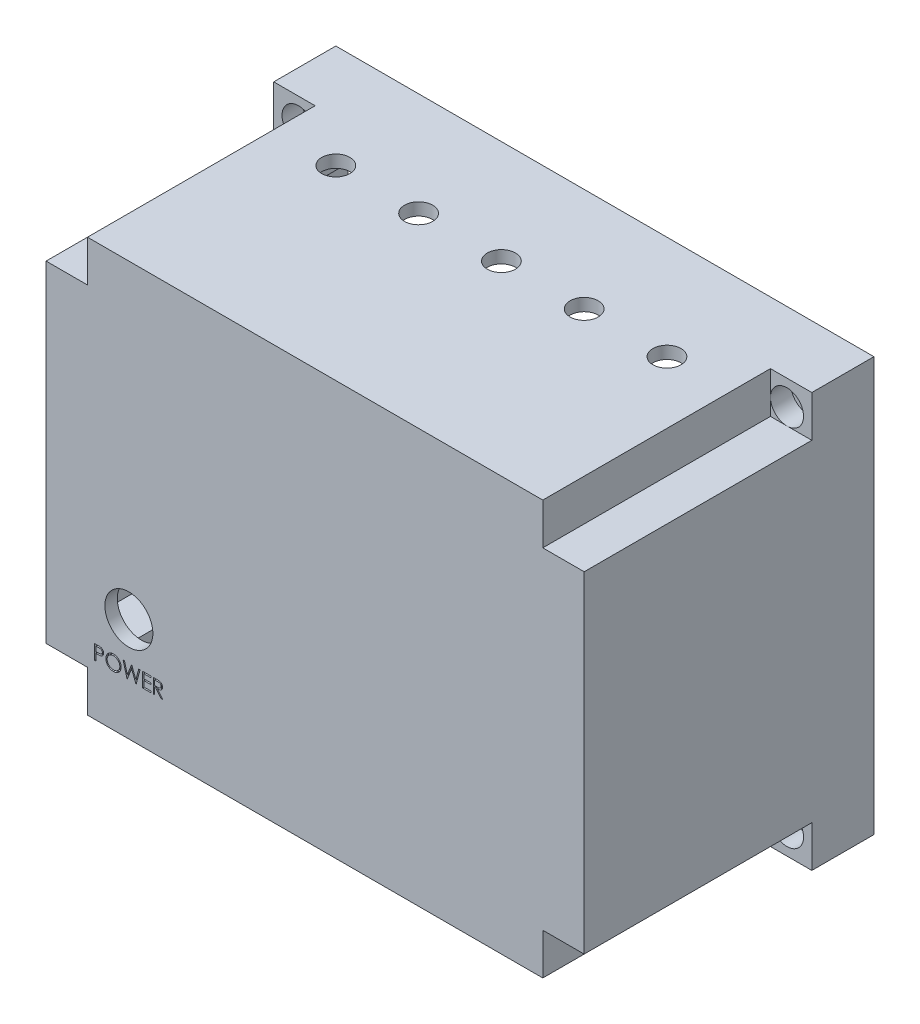
from build123d import *

# Parameters (mm, degrees)
SKETCH2_W           = 130
SKETCH2_H           = 70
BOSS_EXTRUDE1_DEPTH = 100
SKETCH3_W           = 104
SKETCH3_H           = 74
CUT_EXTRUDE1_DEPTH  = 67
SKETCH4_W           = 10
SKETCH4_H           = 10
CUT_EXTRUDE2_DEPTH  = 55
SKETCH5_W           = 104
SKETCH5_H           = 10
CUT_EXTRUDE3_DEPTH  = 67
SKETCH6_W           = 10
SKETCH6_H           = 74
CUT_EXTRUDE4_DEPTH  = 67
SKETCH9_R           = 1.75
CUT_EXTRUDE5_DEPTH  = 67
SKETCH10_R          = 4
CUT_EXTRUDE6_DEPTH  = 5
SKETCH12_R          = 4
CUT_EXTRUDE7_DEPTH  = 5
SKETCH13_R          = 4
CUT_EXTRUDE8_DEPTH  = 5
SKETCH14_R          = 4
CUT_EXTRUDE9_DEPTH  = 5
SKETCH15_W          = 3
SKETCH15_H          = 3
BOSS_EXTRUDE2_DEPTH = 5
SKETCH16_W          = 76
SKETCH16_H          = 3
BOSS_EXTRUDE3_DEPTH = 15
SKETCH17_W          = 3
SKETCH17_H          = 30
BOSS_EXTRUDE4_DEPTH = 15
SKETCH18_R          = 5.8
CUT_EXTRUDE10_DEPTH = 15
SKETCH19_R          = 3.4
CUT_EXTRUDE11_DEPTH = 15
CUT_EXTRUDE12_DEPTH = 0.5


with BuildPart() as part:
    # Sketch2 → Boss-Extrude1 (new body)
    with BuildSketch(Plane(origin=(0, 0, 0), x_dir=(1, 0, 0), z_dir=(0, 1, 0))):
        with Locations((65, 35)):
            Rectangle(SKETCH2_W, SKETCH2_H)
    extrude(amount=BOSS_EXTRUDE1_DEPTH)

    # Sketch3 → Cut-Extrude1 (cut)
    with BuildSketch(Plane(origin=(0, 0, -70), x_dir=(-1, 0, 0), z_dir=(0, 0, -1))):
        with Locations((-65, 50)):
            Rectangle(SKETCH3_W, SKETCH3_H)
    extrude(amount=-CUT_EXTRUDE1_DEPTH, mode=Mode.SUBTRACT)

    # Sketch4 → Cut-Extrude2 (cut)
    with BuildSketch(Plane.XY):
        with Locations((5, 95)):
            Rectangle(SKETCH4_W, SKETCH4_H)
        with Locations((125, 95)):
            Rectangle(SKETCH4_W, SKETCH4_H)
        with Locations((5, 5)):
            Rectangle(SKETCH4_W, SKETCH4_H)
        with Locations((125, 5)):
            Rectangle(SKETCH4_W, SKETCH4_H)
    extrude(amount=-CUT_EXTRUDE2_DEPTH, mode=Mode.SUBTRACT)

    # Sketch5 → Cut-Extrude3 (cut)
    with BuildSketch(Plane(origin=(0, 0, -70), x_dir=(-1, 0, 0), z_dir=(0, 0, -1))):
        with Locations((-65, 92)):
            Rectangle(SKETCH5_W, SKETCH5_H)
        with Locations((-65, 8)):
            Rectangle(SKETCH5_W, SKETCH5_H)
    extrude(amount=-CUT_EXTRUDE3_DEPTH, mode=Mode.SUBTRACT)

    # Sketch6 → Cut-Extrude4 (cut)
    with BuildSketch(Plane(origin=(0, 0, -70), x_dir=(-1, 0, 0), z_dir=(0, 0, -1))):
        with Locations((-122, 50)):
            Rectangle(SKETCH6_W, SKETCH6_H)
        with Locations((-8, 50)):
            Rectangle(SKETCH6_W, SKETCH6_H)
    extrude(amount=-CUT_EXTRUDE4_DEPTH, mode=Mode.SUBTRACT)

    # Sketch9 → Cut-Extrude5 (cut)
    with BuildSketch(Plane(origin=(0, 0, -70), x_dir=(-1, 0, 0), z_dir=(0, 0, -1))):
        with Locations((-124, 94)):
            Circle(SKETCH9_R)
        with Locations((-124, 6)):
            Circle(SKETCH9_R)
        with Locations((-6, 94)):
            Circle(SKETCH9_R)
        with Locations((-6, 6)):
            Circle(SKETCH9_R)
    extrude(amount=-CUT_EXTRUDE5_DEPTH, mode=Mode.SUBTRACT)

    # Sketch10 → Cut-Extrude6 (cut)
    with BuildSketch(Plane.XY.offset(-55)):
        with Locations((124, 94)):
            Circle(SKETCH10_R)
    extrude(amount=-CUT_EXTRUDE6_DEPTH, mode=Mode.SUBTRACT)

    # Sketch12 → Cut-Extrude7 (cut)
    with BuildSketch(Plane.XY.offset(-55)):
        with Locations((124, 6)):
            Circle(SKETCH12_R)
    extrude(amount=-CUT_EXTRUDE7_DEPTH, mode=Mode.SUBTRACT)

    # Sketch13 → Cut-Extrude8 (cut)
    with BuildSketch(Plane.XY.offset(-55)):
        with Locations((6, 6)):
            Circle(SKETCH13_R)
    extrude(amount=-CUT_EXTRUDE8_DEPTH, mode=Mode.SUBTRACT)

    # Sketch14 → Cut-Extrude9 (cut)
    with BuildSketch(Plane.XY.offset(-55)):
        with Locations((6, 94)):
            Circle(SKETCH14_R)
    extrude(amount=-CUT_EXTRUDE9_DEPTH, mode=Mode.SUBTRACT)

    # Sketch15 → Boss-Extrude2 (add)
    with BuildSketch(Plane(origin=(0, 0, -70), x_dir=(-1, 0, 0), z_dir=(0, 0, -1))):
        with Locations((-118.5, 88.5)):
            Rectangle(SKETCH15_W, SKETCH15_H)
        with Locations((-118.5, 11.5)):
            Rectangle(SKETCH15_W, SKETCH15_H)
        with Locations((-11.5, 11.5)):
            Rectangle(SKETCH15_W, SKETCH15_H)
        with Locations((-11.5, 88.5)):
            Rectangle(SKETCH15_W, SKETCH15_H)
    extrude(amount=BOSS_EXTRUDE2_DEPTH)

    # Sketch16 → Boss-Extrude3 (add)
    with BuildSketch(Plane(origin=(0, 3, 0), x_dir=(1, 0, 0), z_dir=(0, 1, 0))):
        with Locations((79, 68.5)):
            Rectangle(SKETCH16_W, SKETCH16_H)
    extrude(amount=BOSS_EXTRUDE3_DEPTH)

    # Sketch17 → Boss-Extrude4 (add)
    with BuildSketch(Plane(origin=(0, 0, -3), x_dir=(-1, 0, 0), z_dir=(0, 0, -1))):
        with Locations((-99.5, 33)):
            Rectangle(SKETCH17_W, SKETCH17_H)
        with Locations((-36.5, 33)):
            Rectangle(SKETCH17_W, SKETCH17_H)
    extrude(amount=BOSS_EXTRUDE4_DEPTH)

    # Sketch18 → Cut-Extrude10 (cut)
    with BuildSketch(Plane(origin=(0, 0, -3), x_dir=(-1, 0, 0), z_dir=(0, 0, -1))):
        with Locations((-20, 25)):
            Circle(SKETCH18_R)
    extrude(amount=-CUT_EXTRUDE10_DEPTH, mode=Mode.SUBTRACT)

    # Sketch19 → Cut-Extrude11 (cut)
    with BuildSketch(Plane(origin=(0, 100, 0), x_dir=(1, 0, 0), z_dir=(0, 1, 0))):
        with Locations((25, 45)):
            Circle(SKETCH19_R)
        with Locations((45, 45)):
            Circle(SKETCH19_R)
        with Locations((65, 45)):
            Circle(SKETCH19_R)
        with Locations((85, 45)):
            Circle(SKETCH19_R)
        with Locations((105, 45)):
            Circle(SKETCH19_R)
    extrude(amount=-CUT_EXTRUDE11_DEPTH, mode=Mode.SUBTRACT)

    # Sketch20 → Cut-Extrude12 (cut)
    with BuildSketch(Plane.XY):
        with BuildLine():
            Line((11.755848819, 15.843775978), (12.442247056, 15.843775978))
            add(Edge.make_bspline(
                [(12.442247056, 15.843775978), (12.489457962, 15.843724082), (12.579916155, 15.843624646), (12.709631211, 15.8406099), (12.827440942, 15.836583208), (12.933091323, 15.831001315), (13.026907421, 15.824404725), (13.108464721, 15.815152686), (13.178404277, 15.80549239), (13.220310727, 15.795670983), (13.239422537, 15.791191843)],
                knots=[0, 0, 0, 0, 0.000141628, 0.000271366, 0.00038923, 0.000495248, 0.00058876, 0.000671296, 0.000741499, 0.00080036, 0.00080036, 0.00080036, 0.00080036], degree=3))
            add(Edge.make_bspline(
                [(13.239422537, 15.791191843), (13.263616071, 15.784569894), (13.311433048, 15.771482032), (13.380334091, 15.745268308), (13.445887936, 15.714186143), (13.508319495, 15.678762203), (13.566861578, 15.637476639), (13.622387619, 15.592003021), (13.674407599, 15.541291453), (13.722628991, 15.485910713), (13.766913789, 15.426790503), (13.805043471, 15.363048273), (13.836970698, 15.29575697), (13.86435397, 15.224963399), (13.884062424, 15.150073075), (13.898909324, 15.071606363), (13.908332952, 14.989571673), (13.909235513, 14.933511805), (13.909694973, 14.904973895)],
                knots=[0, 0, 0, 0, 7.5216e-05, 0.00014866, 0.000220794, 0.000292713, 0.000363707, 0.000435434, 0.000507823, 0.000581364, 0.000655543, 0.000729131, 0.000803767, 0.000878771, 0.000956497, 0.001035702, 0.001118238, 0.001203821, 0.001203821, 0.001203821, 0.001203821], degree=3))
            add(Edge.make_bspline(
                [(13.909694973, 14.904973895), (13.909273548, 14.876196118), (13.908449002, 14.819890454), (13.898552717, 14.737517666), (13.885222525, 14.658799276), (13.864725473, 14.583909825), (13.8378798, 14.513294055), (13.806387747, 14.445872823), (13.768404216, 14.382793151), (13.724759387, 14.323826033), (13.676207792, 14.268916121), (13.622954854, 14.218461326), (13.565215562, 14.172756988), (13.503173414, 14.131700644), (13.436223565, 14.096244365), (13.365381411, 14.06448706), (13.290031195, 14.037815999), (13.237888681, 14.023785938), (13.211377665, 14.016652581)],
                knots=[0, 0, 0, 0, 8.6284e-05, 0.00016882, 0.000248587, 0.000325638, 0.000401297, 0.000474998, 0.000548586, 0.000621785, 0.0006948, 0.0007682, 0.000841564, 0.000915458, 0.000991056, 0.00106858, 0.00114819, 0.001230532, 0.001230532, 0.001230532, 0.001230532], degree=3))
            add(Edge.make_bspline(
                [(13.211377665, 14.016652581), (13.189450331, 14.0119896), (13.141395304, 14.001770405), (13.062252582, 13.990361949), (12.970107196, 13.980624348), (12.865084916, 13.97332321), (12.747280011, 13.967072842), (12.616628753, 13.962104748), (12.472874676, 13.959374894), (12.372603432, 13.959234101), (12.320251864, 13.959160593)],
                knots=[0, 0, 0, 0, 6.7238e-05, 0.000147357, 0.000239727, 0.000345177, 0.000463135, 0.000593636, 0.000737393, 0.000894446, 0.000894446, 0.000894446, 0.000894446], degree=3))
            Line((12.320251864, 13.959160593), (12.069951383, 13.959160593))
            Line((12.069951383, 13.959160593), (12.069951383, 12.343775978))
            Line((12.069951383, 12.343775978), (11.755848819, 12.343775978))
            Line((11.755848819, 12.343775978), (11.755848819, 15.843775978))
        make_face()
        with BuildLine():
            Line((12.069951383, 15.484801619), (12.069951383, 14.318134952))
            Line((12.069951383, 14.318134952), (12.682731832, 14.310422613))
            add(Edge.make_bspline(
                [(12.682731832, 14.310422613), (12.712651758, 14.310407149), (12.770411557, 14.310377297), (12.853847781, 14.31436252), (12.931257068, 14.318963053), (13.002401643, 14.325698977), (13.067313578, 14.335220234), (13.126101107, 14.344831972), (13.17830839, 14.358737335), (13.239407591, 14.377460404), (13.307490939, 14.409393019), (13.381558487, 14.455742909), (13.444329074, 14.514823618), (13.498647371, 14.581251449), (13.541753248, 14.655150578), (13.573309241, 14.734219515), (13.591850398, 14.817647365), (13.594336592, 14.874735503), (13.595592409, 14.903571651)],
                knots=[0, 0, 0, 0, 8.9746e-05, 0.000173253, 0.000250533, 0.00032239, 0.000387534, 0.00044736, 0.000500926, 0.000549486, 0.000638903, 0.000725641, 0.000810488, 0.000896226, 0.000982324, 0.00106604, 0.001150757, 0.001237226, 0.001237226, 0.001237226, 0.001237226], degree=3))
            add(Edge.make_bspline(
                [(13.595592409, 14.903571651), (13.594329762, 14.931710165), (13.591819777, 14.987646047), (13.573163914, 15.069624807), (13.5418146, 15.147860512), (13.498358006, 15.220833597), (13.445616876, 15.287022401), (13.384317533, 15.344519528), (13.314604271, 15.390741231), (13.24975604, 15.420574512), (13.192154854, 15.438789788), (13.142122894, 15.451534628), (13.08563222, 15.461710235), (13.02266444, 15.469949737), (12.953707606, 15.477003199), (12.878169292, 15.481789176), (12.796335648, 15.484590632), (12.739525077, 15.484729587), (12.710075582, 15.484801619)],
                knots=[0, 0, 0, 0, 8.4371e-05, 0.000167719, 0.000250783, 0.000336277, 0.000421575, 0.000503926, 0.000587348, 0.000671427, 0.000717102, 0.000768457, 0.000826213, 0.000889178, 0.000958942, 0.001034123, 0.001116202, 0.001204546, 0.001204546, 0.001204546, 0.001204546], degree=3))
            Line((12.710075582, 15.484801619), (12.069951383, 15.484801619))
        make_face(mode=Mode.SUBTRACT)
        with BuildLine():
            add(Edge.make_bspline(
                [(16.265464204, 15.933519568), (16.330272309, 15.931878088), (16.457560776, 15.928654087), (16.644635674, 15.903974984), (16.823230769, 15.861279594), (16.994800908, 15.804416611), (17.157293885, 15.728562226), (17.311932777, 15.636877078), (17.458349651, 15.528400619), (17.594571033, 15.403971392), (17.719227983, 15.268587938), (17.829053869, 15.124110028), (17.921096163, 14.971411226), (17.99668195, 14.810950395), (18.05598056, 14.643090427), (18.096899603, 14.466936425), (18.123037754, 14.283629734), (18.126093531, 14.15860287), (18.127643691, 14.095178222)],
                knots=[0, 0, 0, 0, 0.000194393, 0.000381804, 0.00056479, 0.000744601, 0.000923091, 0.001101652, 0.001283106, 0.001468738, 0.001654324, 0.001834514, 0.002012231, 0.002188181, 0.002365797, 0.002545211, 0.002729936, 0.002920126, 0.002920126, 0.002920126, 0.002920126], degree=3))
            add(Edge.make_bspline(
                [(18.127643691, 14.095178222), (18.126093758, 14.032220775), (18.123038662, 13.908124355), (18.096869884, 13.725980911), (18.055828884, 13.550890214), (17.997232618, 13.383144561), (17.922007139, 13.222566998), (17.829351968, 13.069580044), (17.720210758, 12.924133545), (17.596003907, 12.78782088), (17.460602865, 12.662823409), (17.315372598, 12.553904534), (17.163579278, 12.460180409), (17.00326957, 12.385396735), (16.836569533, 12.325624815), (16.66198721, 12.284872185), (16.480340656, 12.258585141), (16.356469652, 12.255566626), (16.293509075, 12.254032388)],
                knots=[0, 0, 0, 0, 0.000188789, 0.000372126, 0.000550857, 0.00072758, 0.000904164, 0.001081881, 0.001263191, 0.001448823, 0.00163441, 0.001815159, 0.001992641, 0.002168591, 0.002344885, 0.002522934, 0.002705576, 0.002894365, 0.002894365, 0.002894365, 0.002894365], degree=3))
            add(Edge.make_bspline(
                [(16.293509075, 12.254032388), (16.230084756, 12.255581775), (16.10505854, 12.258636029), (15.921521505, 12.284817434), (15.745243761, 12.325758738), (15.57672941, 12.384268174), (15.41588448, 12.459885405), (15.262394398, 12.552089784), (15.11687525, 12.661496925), (14.980533504, 12.785663499), (14.855784306, 12.920835051), (14.74702493, 13.065669307), (14.654799817, 13.217324763), (14.579436484, 13.376222287), (14.519772025, 13.54159373), (14.479067207, 13.714542207), (14.452731255, 13.894081713), (14.449696408, 14.016324612), (14.448156511, 14.078351299)],
                knots=[0, 0, 0, 0, 0.00019019, 0.000374915, 0.000555011, 0.000732396, 0.00090898, 0.001087298, 0.001268608, 0.00145424, 0.001639827, 0.001819595, 0.001996712, 0.002171394, 0.002346367, 0.002523053, 0.002703612, 0.002889599, 0.002889599, 0.002889599, 0.002889599], degree=3))
            add(Edge.make_bspline(
                [(14.448156511, 14.078351299), (14.448691147, 14.119983968), (14.449753673, 14.202724091), (14.462545366, 14.325590691), (14.481107067, 14.446481349), (14.507708979, 14.565052297), (14.542500646, 14.681013282), (14.583552674, 14.795164045), (14.633692519, 14.906347768), (14.690373167, 15.01509116), (14.753634975, 15.119699066), (14.823510725, 15.218578649), (14.897546093, 15.312559646), (14.978709487, 15.39920665), (15.064325932, 15.481040306), (15.15578431, 15.556803023), (15.252526554, 15.627177974), (15.354968934, 15.690598315), (15.460587209, 15.74795745), (15.569463987, 15.797179301), (15.680120558, 15.839425362), (15.793075206, 15.873666187), (15.908027978, 15.900698223), (16.025229763, 15.919105577), (16.144587189, 15.931929895), (16.224998508, 15.932987397), (16.265464204, 15.933519568)],
                knots=[0, 0, 0, 0, 0.000124849, 0.000248123, 0.000370193, 0.00049164, 0.000612319, 0.000733199, 0.000855287, 0.000977905, 0.001100913, 0.001221706, 0.001340948, 0.001459521, 0.001577551, 0.001696047, 0.001815534, 0.001936153, 0.002057243, 0.002175846, 0.002294342, 0.002412335, 0.002529682, 0.00264829, 0.002768075, 0.00288942, 0.00288942, 0.00288942, 0.00288942], degree=3))
        make_face()
        with BuildLine():
            add(Edge.make_bspline(
                [(16.280888883, 15.574545209), (16.247674249, 15.574140319), (16.181562517, 15.573334409), (16.08327798, 15.562718693), (15.986286046, 15.547588804), (15.890566684, 15.526007284), (15.796520395, 15.496603231), (15.703270554, 15.462762323), (15.6116675, 15.421541232), (15.522013642, 15.374968528), (15.435098567, 15.323419607), (15.353085865, 15.26644784), (15.275763221, 15.205389285), (15.203319955, 15.140101448), (15.135968783, 15.070251846), (15.072384081, 14.99689941), (15.0151145, 14.917947519), (14.962628923, 14.835537112), (14.915661082, 14.749775531), (14.873895728, 14.661565669), (14.839731719, 14.570187982), (14.811869343, 14.476633824), (14.788769532, 14.381051365), (14.774135608, 14.282715516), (14.763403248, 14.182120404), (14.762643403, 14.11413855), (14.762259075, 14.079753542)],
                knots=[0, 0, 0, 0, 9.9599e-05, 0.000198245, 0.000296222, 0.00039402, 0.00049227, 0.000591646, 0.000691452, 0.000793368, 0.000894612, 0.000994383, 0.001092713, 0.00119001, 0.001286696, 0.001383657, 0.001480979, 0.001579008, 0.001676595, 0.001774142, 0.001871547, 0.001968922, 0.002066879, 0.00216624, 0.00226698, 0.002370083, 0.002370083, 0.002370083, 0.002370083], degree=3))
            add(Edge.make_bspline(
                [(14.762259075, 14.079753542), (14.763533937, 14.029191321), (14.766041985, 13.929719791), (14.787999555, 13.783951647), (14.82182153, 13.643863361), (14.871678896, 13.510221452), (14.934029511, 13.381877169), (15.011056401, 13.259969064), (15.102315487, 13.14446419), (15.205979013, 13.036168921), (15.31930172, 12.937323116), (15.43963445, 12.850559708), (15.565688057, 12.777149458), (15.69779126, 12.717344386), (15.835238799, 12.669954648), (15.97891635, 12.637476017), (16.12786681, 12.616100561), (16.229397465, 12.614047805), (16.280888883, 12.613006747)],
                knots=[0, 0, 0, 0, 0.000151605, 0.000298253, 0.000441263, 0.000583229, 0.000725274, 0.000868635, 0.001014928, 0.001166177, 0.001317744, 0.00146543, 0.001610576, 0.001754594, 0.001899821, 0.002045914, 0.002195936, 0.002350312, 0.002350312, 0.002350312, 0.002350312], degree=3))
            add(Edge.make_bspline(
                [(16.280888883, 12.613006747), (16.315498385, 12.613482252), (16.384139421, 12.61442532), (16.486234943, 12.623923996), (16.586491155, 12.639155866), (16.684767435, 12.661086521), (16.780952246, 12.688533728), (16.875447049, 12.721141456), (16.96724534, 12.76182266), (17.057505178, 12.806770611), (17.143901419, 12.858010769), (17.226376952, 12.913048918), (17.302852931, 12.974017539), (17.375242003, 13.038335352), (17.442869692, 13.107299199), (17.505278676, 13.180819421), (17.562258808, 13.259360078), (17.614724455, 13.341645484), (17.661527718, 13.427641737), (17.702306817, 13.516171415), (17.736902932, 13.607016524), (17.764831437, 13.700308096), (17.786716899, 13.795868944), (17.801796819, 13.893827023), (17.812345258, 13.993986365), (17.813140335, 14.061730221), (17.813541127, 14.095879343)],
                knots=[0, 0, 0, 0, 0.000103804, 0.000205874, 0.000307314, 0.000407849, 0.000507719, 0.000607281, 0.000707445, 0.000808723, 0.000909609, 0.001008589, 0.001105934, 0.001202762, 0.001298946, 0.001395452, 0.001491794, 0.001589823, 0.001688026, 0.001785277, 0.001882027, 0.001979402, 0.0020772, 0.002175869, 0.002276609, 0.002379011, 0.002379011, 0.002379011, 0.002379011], degree=3))
            add(Edge.make_bspline(
                [(17.813541127, 14.095879343), (17.813140014, 14.129794848), (17.812344332, 14.197072498), (17.801801858, 14.296533316), (17.786700967, 14.393786528), (17.764938259, 14.488450331), (17.736888105, 14.580548856), (17.702300775, 14.669995603), (17.661515475, 14.757123799), (17.614707251, 14.841718096), (17.562091428, 14.922892834), (17.504597184, 15.000495246), (17.441231836, 15.073067987), (17.373805811, 15.142402681), (17.300634926, 15.207020571), (17.222050632, 15.266943092), (17.139006954, 15.323616366), (17.051079719, 15.374741928), (16.960335765, 15.421956161), (16.867221807, 15.462407164), (16.772792707, 15.496779283), (16.677288595, 15.526096248), (16.579905617, 15.547504278), (16.481301788, 15.562732328), (16.381613529, 15.573330714), (16.31457031, 15.574139093), (16.280888883, 15.574545209)],
                knots=[0, 0, 0, 0, 0.000101701, 0.000201743, 0.00029972, 0.000396835, 0.000492868, 0.000588308, 0.000684288, 0.000781261, 0.000878109, 0.000974304, 0.001070733, 0.001166917, 0.001264269, 0.001363274, 0.001463228, 0.001565678, 0.001668217, 0.001769947, 0.001869982, 0.001969573, 0.002069423, 0.002168785, 0.002268827, 0.002369827, 0.002369827, 0.002369827, 0.002369827], degree=3))
        make_face(mode=Mode.SUBTRACT)
        Polygon((18.621233434, 15.843775978), (18.945852825, 15.843775978), (19.630848819, 13.276969087), (20.649578787, 15.843775978), (20.695151704, 15.843775978), (21.694951383, 13.294497132), (22.383452986, 15.843775978), (22.704566768, 15.843775978), (21.760856832, 12.343775978), (21.715985037, 12.343775978), (20.662900101, 15.020658991), (19.597194973, 12.343775978), (19.552323178, 12.343775978), align=None)
        Polygon((23.332771896, 15.843775978), (25.30713087, 15.843775978), (25.30713087, 15.484801619), (23.64687446, 15.484801619), (23.64687446, 14.407878542), (25.30713087, 14.407878542), (25.30713087, 14.048904183), (23.64687446, 14.048904183), (23.64687446, 12.702750337), (25.30713087, 12.702750337), (25.30713087, 12.343775978), (23.332771896, 12.343775978), align=None)
        with BuildLine():
            Line((25.935335998, 15.843775978), (26.635756671, 15.843775978))
            add(Edge.make_bspline(
                [(26.635756671, 15.843775978), (26.6824978, 15.843620392), (26.772245944, 15.84332165), (26.900819215, 15.841655887), (27.017646312, 15.836881531), (27.122666151, 15.832772948), (27.215876806, 15.825281006), (27.297564097, 15.818120359), (27.367351794, 15.808746698), (27.409597646, 15.800041275), (27.428725421, 15.796099696)],
                knots=[0, 0, 0, 0, 0.000140226, 0.00026925, 0.000385712, 0.000490995, 0.000584507, 0.000666202, 0.000736998, 0.000795574, 0.000795574, 0.000795574, 0.000795574], degree=3))
            add(Edge.make_bspline(
                [(27.428725421, 15.796099696), (27.454332046, 15.789772931), (27.504999035, 15.777254367), (27.577949101, 15.750794766), (27.647463425, 15.720175142), (27.713253249, 15.684211421), (27.774989041, 15.642636642), (27.833307351, 15.596168519), (27.888472815, 15.545061313), (27.938254445, 15.488026472), (27.985193497, 15.428189962), (28.024782123, 15.363486205), (28.058908603, 15.295824678), (28.08607912, 15.22451726), (28.107957093, 15.150255488), (28.123383333, 15.072366691), (28.13263452, 14.991205716), (28.133576376, 14.935847808), (28.134053947, 14.907778382)],
                knots=[0, 0, 0, 0, 7.9081e-05, 0.000156475, 0.000232432, 0.000306798, 0.00038108, 0.000455429, 0.000530331, 0.000606314, 0.000682321, 0.000758201, 0.000833453, 0.000909362, 0.000986794, 0.001065445, 0.001147284, 0.001231465, 0.001231465, 0.001231465, 0.001231465], degree=3))
            add(Edge.make_bspline(
                [(28.134053947, 14.907778382), (28.132584949, 14.861143277), (28.129718553, 14.770146109), (28.10299345, 14.638085228), (28.05921693, 14.514895913), (27.998893641, 14.400733275), (27.922074165, 14.29782263), (27.829749374, 14.207432175), (27.721867762, 14.131792262), (27.621438447, 14.079339457), (27.532724247, 14.045746549), (27.459690934, 14.02211019), (27.380023957, 14.003848225), (27.294486622, 13.987488093), (27.202722966, 13.975136399), (27.104952927, 13.966089804), (27.001106775, 13.960435755), (26.929767706, 13.95959375), (26.89306837, 13.959160593)],
                knots=[0, 0, 0, 0, 0.000139777, 0.000272741, 0.000402249, 0.000530843, 0.000658588, 0.000786009, 0.000916741, 0.001052522, 0.001124656, 0.001201155, 0.001282612, 0.001369656, 0.001462366, 0.001560247, 0.001664165, 0.001774261, 0.001774261, 0.001774261, 0.001774261], degree=3))
            Line((26.89306837, 13.959160593), (28.178925742, 12.343775978))
            Line((28.178925742, 12.343775978), (27.790504268, 12.343775978))
            Line((27.790504268, 12.343775978), (26.504646896, 13.959160593))
            Line((26.504646896, 13.959160593), (26.249438562, 13.959160593))
            Line((26.249438562, 13.959160593), (26.249438562, 12.343775978))
            Line((26.249438562, 12.343775978), (25.935335998, 12.343775978))
            Line((25.935335998, 12.343775978), (25.935335998, 15.843775978))
        make_face()
        with BuildLine():
            Line((26.249438562, 15.484801619), (26.249438562, 14.318134952))
            Line((26.249438562, 14.318134952), (26.890263883, 14.3132271))
            add(Edge.make_bspline(
                [(26.890263883, 14.3132271), (26.920183922, 14.313213863), (26.978177479, 14.313188207), (27.062078144, 14.317181983), (27.140198256, 14.321725301), (27.212239008, 14.328674647), (27.278232583, 14.337630719), (27.338145996, 14.348833703), (27.392077048, 14.361885765), (27.454975587, 14.382087391), (27.525212118, 14.414093409), (27.601543578, 14.460658908), (27.666545916, 14.519228027), (27.721463778, 14.586201483), (27.765593209, 14.659837732), (27.796705264, 14.739254101), (27.816447706, 14.822445699), (27.818776251, 14.879623807), (27.819951383, 14.908479504)],
                knots=[0, 0, 0, 0, 8.9746e-05, 0.000173954, 0.000251933, 0.000324488, 0.000391021, 0.000451663, 0.000507268, 0.000557378, 0.000649639, 0.000738152, 0.000824558, 0.000910739, 0.000997194, 0.001080909, 0.00116578, 0.001252248, 0.001252248, 0.001252248, 0.001252248], degree=3))
            add(Edge.make_bspline(
                [(27.819951383, 14.908479504), (27.818749262, 14.936626077), (27.816367097, 14.992402316), (27.796918328, 15.074058226), (27.764028947, 15.151125176), (27.719706709, 15.223289661), (27.665707554, 15.288795397), (27.602389741, 15.34484255), (27.531484546, 15.391092015), (27.465213348, 15.420646396), (27.405979135, 15.438766249), (27.354549475, 15.451517413), (27.296437997, 15.461761882), (27.231362539, 15.469969942), (27.159600908, 15.477024887), (27.080790257, 15.481776665), (26.995453477, 15.484590529), (26.936306545, 15.484729618), (26.905688562, 15.484801619)],
                knots=[0, 0, 0, 0, 8.4371e-05, 0.000167192, 0.000250141, 0.000334794, 0.000420435, 0.000503871, 0.000587493, 0.000673488, 0.0007205, 0.000773215, 0.000832351, 0.0008974, 0.000969955, 0.001048634, 0.001134217, 0.001226067, 0.001226067, 0.001226067, 0.001226067], degree=3))
            Line((26.905688562, 15.484801619), (26.249438562, 15.484801619))
        make_face(mode=Mode.SUBTRACT)
    extrude(amount=-CUT_EXTRUDE12_DEPTH, mode=Mode.SUBTRACT)


solid = part.part
